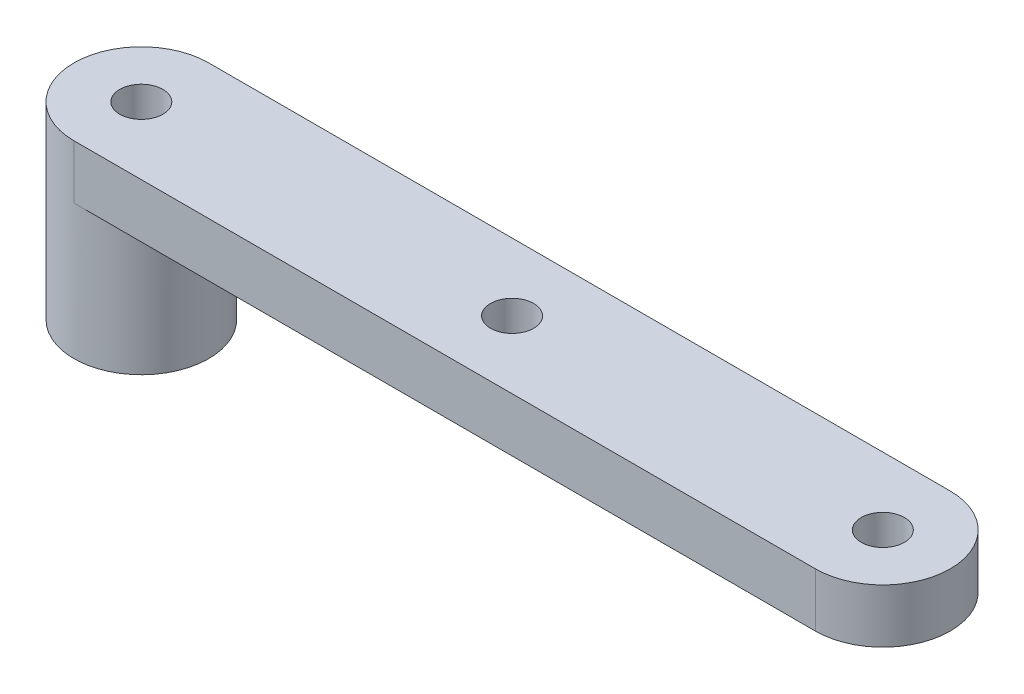
from build123d import *

# Parameters (mm, degrees)
BOSS_EXTRUDE1_DEPTH = 4
SKETCH3_R           = 5
BOSS_EXTRUDE2_DEPTH = 10
SKETCH2_R           = 1.6
CUT_EXTRUDE1_DEPTH  = 15


with BuildPart() as part:
    # Sketch1 → Boss-Extrude1 (new body)
    with BuildSketch(Plane(origin=(0, 0, 0), x_dir=(1, 0, 0), z_dir=(0, 1, 0))):
        with BuildLine():
            Line((0, 5), (55, 5))
            ThreePointArc((55, 5), (60, 0), (55, -5))
            Line((55, -5), (0, -5))
            ThreePointArc((0, -5), (-5, 0), (0, 5))
        make_face()
    extrude(amount=BOSS_EXTRUDE1_DEPTH)

    # Sketch3 → Boss-Extrude2 (add)
    with BuildSketch(Plane.XZ):
        Circle(SKETCH3_R)
    extrude(amount=BOSS_EXTRUDE2_DEPTH)

    # Sketch2 → Cut-Extrude1 (cut, through all)
    with BuildSketch(Plane(origin=(0, 4, 0), x_dir=(1, 0, 0), z_dir=(0, 1, 0))):
        Circle(SKETCH2_R)
        with Locations((27.5, 0)):
            Circle(SKETCH2_R)
        with Locations((55, 0)):
            Circle(SKETCH2_R)
    extrude(amount=-CUT_EXTRUDE1_DEPTH, mode=Mode.SUBTRACT)


solid = part.part
